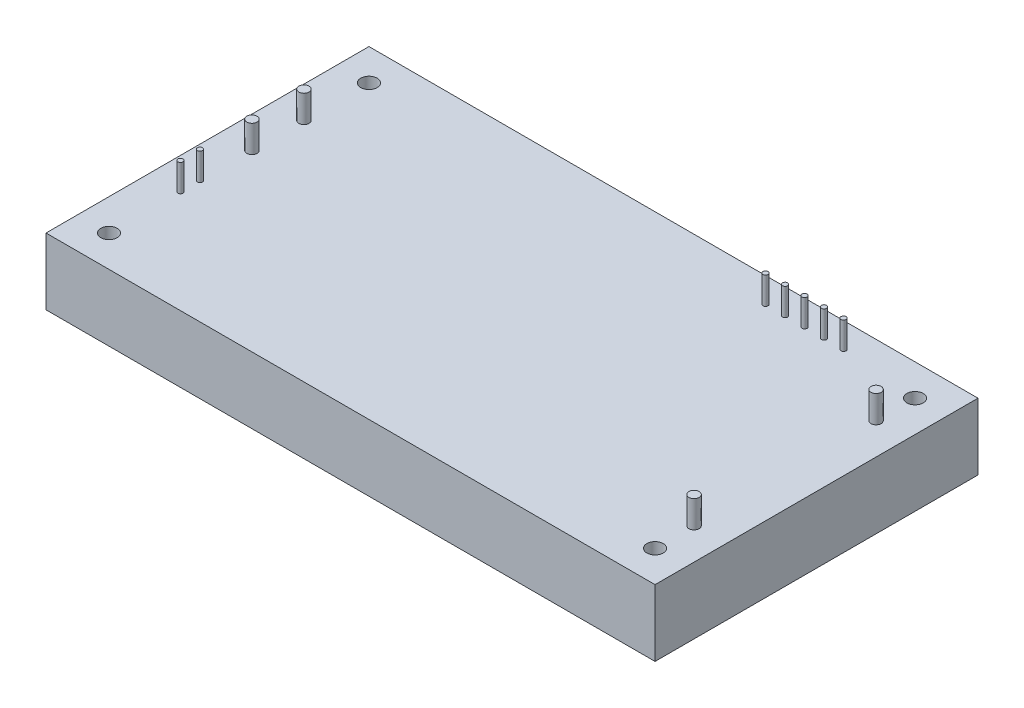
from build123d import *

# Parameters (mm, degrees)
SKETCH_1_W          = 119
SKETCH_1_H          = 63.1
EXTRUDE_1_DEPTH     = 13
SKETCH_2_R          = 1.6
CUT_EXTRUDE_2_DEPTH = 13
SKETCH_3_R          = 1
EXTRUDE_2_DEPTH     = 5.3
SKETCH_4_R          = 0.5
EXTRUDE_3_DEPTH     = 5.3


with BuildPart() as part:
    # 草图1 → 凸台-拉伸1 (new body)
    with BuildSketch(Plane(origin=(0, 0, 0), x_dir=(1, 0, 0), z_dir=(0, 1, 0))):
        Rectangle(SKETCH_1_W, SKETCH_1_H)
    extrude(amount=EXTRUDE_1_DEPTH)

    # 草图2 → 切除-拉伸2 (cut)
    with BuildSketch(Plane(origin=(0, 13, 0), x_dir=(1, 0, 0), z_dir=(0, 1, 0))):
        with Locations((53.35, 25.4)):
            Circle(SKETCH_2_R)
        with Locations((53.35, -25.4)):
            Circle(SKETCH_2_R)
        with Locations((-53.35, 25.4)):
            Circle(SKETCH_2_R)
        with Locations((-53.35, -25.4)):
            Circle(SKETCH_2_R)
    extrude(amount=-CUT_EXTRUDE_2_DEPTH, mode=Mode.SUBTRACT)

    # 草图3 → 凸台-拉伸2 (add)
    with BuildSketch(Plane(origin=(0, 13, 0), x_dir=(1, 0, 0), z_dir=(0, 1, 0))):
        with Locations((53.35, 17.78)):
            Circle(SKETCH_3_R)
        with Locations((53.35, -17.78)):
            Circle(SKETCH_3_R)
        with Locations((-53.35, 12.7)):
            Circle(SKETCH_3_R)
        with Locations((-53.35, 2.54)):
            Circle(SKETCH_3_R)
    extrude(amount=EXTRUDE_2_DEPTH)

    # 草图4 → 凸台-拉伸3 (add)
    with BuildSketch(Plane(origin=(0, 13, 0), x_dir=(1, 0, 0), z_dir=(0, 1, 0))):
        with Locations((-53.35, -7.62)):
            Circle(SKETCH_4_R)
        with Locations((-53.35, -11.43)):
            Circle(SKETCH_4_R)
        with Locations((34.3, 26.67)):
            Circle(SKETCH_4_R)
        with Locations((38.11, 26.67)):
            Circle(SKETCH_4_R)
        with Locations((30.49, 26.67)):
            Circle(SKETCH_4_R)
        with Locations((26.68, 26.67)):
            Circle(SKETCH_4_R)
        with Locations((22.87, 26.67)):
            Circle(SKETCH_4_R)
    extrude(amount=EXTRUDE_3_DEPTH)


solid = part.part
